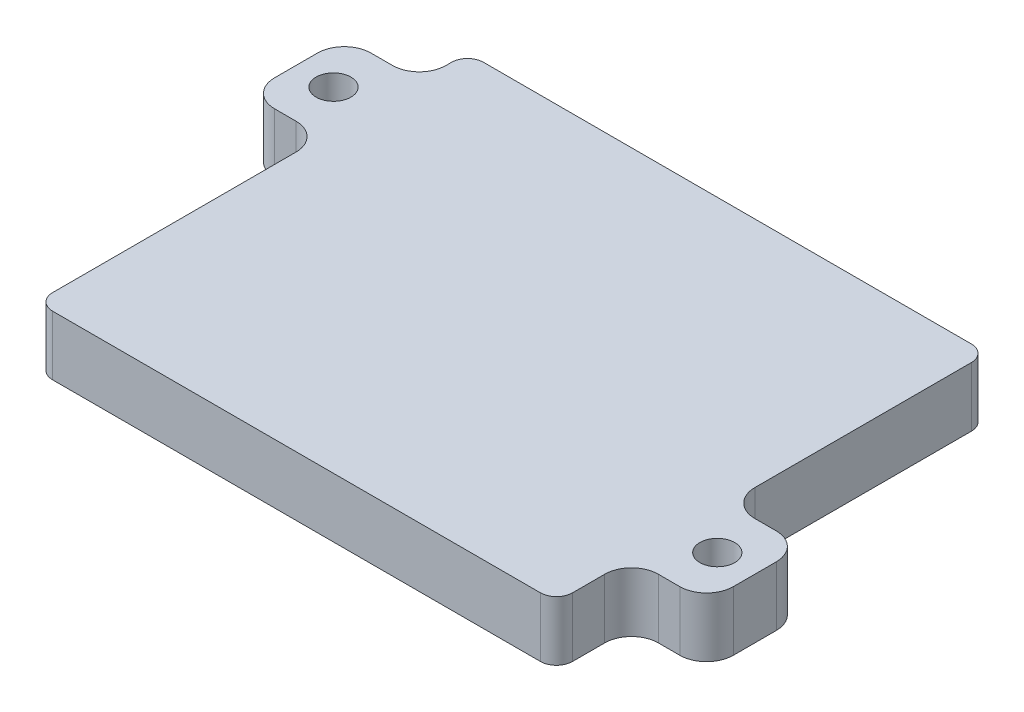
from build123d import *

# Parameters (mm, degrees)
SKETCH1_W           = 97
SKETCH1_H           = 80.401218893
BOSS_EXTRUDE1_DEPTH = 12.6
CUT_EXTRUDE2_START  = -5
CUT_EXTRUDE2_DEPTH  = 10
SKETCH6_W           = 97
SKETCH6_H           = 80.401218893
CUT_EXTRUDE3_DEPTH  = 1.5
FILLET1_R           = 3
SKETCH7_W           = 18
SKETCH7_H           = 11.1
BOSS_EXTRUDE2_DEPTH = 14
SKETCH8_W           = 18
SKETCH8_H           = 11.1
BOSS_EXTRUDE3_DEPTH = 14
FILLET2_R           = 5
SKETCH9_R           = 3.25
CUT_EXTRUDE4_DEPTH  = 13.6


with BuildPart() as part:
    # Sketch1 → Boss-Extrude1 (new body)
    with BuildSketch(Plane(origin=(0, 0, 0), x_dir=(1, 0, 0), z_dir=(0, 1, 0))):
        with Locations((3.433898335, -1.804923378)):
            Rectangle(SKETCH1_W, SKETCH1_H)
    extrude(amount=BOSS_EXTRUDE1_DEPTH)

    # Sketch3 → Cut-Extrude2 (cut)
    with BuildSketch(Plane(origin=(0, 12.6, 0), x_dir=(1, 0, 0), z_dir=(0, 1, 0)).offset(CUT_EXTRUDE2_START)):
        with BuildLine():
            Line((-41.366101665, 31.831649434), (-41.366101665, -34.168350566))
            ThreePointArc((-41.366101665, -34.168350566), (-40.926761836, -35.229010737), (-39.866101665, -35.668350566))
            Line((-39.866101665, -35.668350566), (46.133898335, -35.668350566))
            ThreePointArc((46.133898335, -35.668350566), (47.194558507, -35.229010737), (47.633898335, -34.168350566))
            Line((47.633898335, -34.168350566), (47.633898335, 31.831649434))
            ThreePointArc((47.633898335, 31.831649434), (47.194558507, 32.892309606), (46.133898335, 33.331649434))
            Line((46.133898335, 33.331649434), (-39.866101665, 33.331649434))
            ThreePointArc((-39.866101665, 33.331649434), (-40.926761836, 32.892309606), (-41.366101665, 31.831649434))
        make_face()
    extrude(amount=-CUT_EXTRUDE2_DEPTH, mode=Mode.SUBTRACT)

    # Sketch6 → Cut-Extrude3 (cut)
    with BuildSketch(Plane.XZ):
        with Locations((3.433898335, 1.804923378)):
            Rectangle(SKETCH6_W, SKETCH6_H)
        with BuildLine():
            Line((-39.866101665, -34.331649434), (46.133898335, -34.331649434))
            ThreePointArc((46.133898335, -34.331649434), (47.901665288, -33.599416387), (48.633898335, -31.831649434))
            Line((48.633898335, -31.831649434), (48.633898335, 34.168350566))
            ThreePointArc((48.633898335, 34.168350566), (47.901665288, 35.936117519), (46.133898335, 36.668350566))
            Line((46.133898335, 36.668350566), (-39.866101665, 36.668350566))
            ThreePointArc((-39.866101665, 36.668350566), (-41.633868617, 35.936117519), (-42.366101665, 34.168350566))
            Line((-42.366101665, 34.168350566), (-42.366101665, -31.831649434))
            ThreePointArc((-42.366101665, -31.831649434), (-41.633868617, -33.599416387), (-39.866101665, -34.331649434))
        make_face(mode=Mode.SUBTRACT)
    extrude(amount=-CUT_EXTRUDE3_DEPTH, mode=Mode.SUBTRACT)

    # Fillet1
    fillet1_edges = [part.edges().sort_by_distance(p)[0] for p in [
        (51.933898335, 7.05, 42.005532825),
        (-45.066101665, 7.05, 42.005532825),
        (-45.066101665, 7.05, -38.395686068),
        (51.933898335, 7.05, -38.395686068),
    ]]
    fillet(fillet1_edges, radius=FILLET1_R)

    # Sketch7 → Boss-Extrude2 (add)
    with BuildSketch(Plane.ZY.offset(45.066101665)):
        with Locations((-20.395686068, 7.05)):
            Rectangle(SKETCH7_W, SKETCH7_H)
    extrude(amount=BOSS_EXTRUDE2_DEPTH)

    # Sketch8 → Boss-Extrude3 (add)
    with BuildSketch(Plane(origin=(51.933898335, 0, 0), x_dir=(0, 0, -1), z_dir=(1, 0, 0))):
        with Locations((-19.005532825, 7.05)):
            Rectangle(SKETCH8_W, SKETCH8_H)
    extrude(amount=BOSS_EXTRUDE3_DEPTH)

    # Fillet2
    fillet2_edges = [part.edges().sort_by_distance(p)[0] for p in [
        (-45.066101665, 7.05, -11.395686068),
        (-45.066101665, 7.05, -29.395686068),
        (-59.066101665, 7.05, -11.395686068),
        (-59.066101665, 7.05, -29.395686068),
        (51.933898335, 7.05, 10.005532825),
        (51.933898335, 7.05, 28.005532825),
        (65.933898335, 7.05, 10.005532825),
        (65.933898335, 7.05, 28.005532825),
    ]]
    fillet(fillet2_edges, radius=FILLET2_R)

    # Sketch9 → Cut-Extrude4 (cut, through all)
    with BuildSketch(Plane(origin=(0, 12.6, 0), x_dir=(1, 0, 0), z_dir=(0, 1, 0))):
        with Locations((58.933898335, -19.005532825)):
            Circle(SKETCH9_R)
        with Locations((-52.066101665, 20.395686068)):
            Circle(SKETCH9_R)
    extrude(amount=-CUT_EXTRUDE4_DEPTH, mode=Mode.SUBTRACT)


solid = part.part
